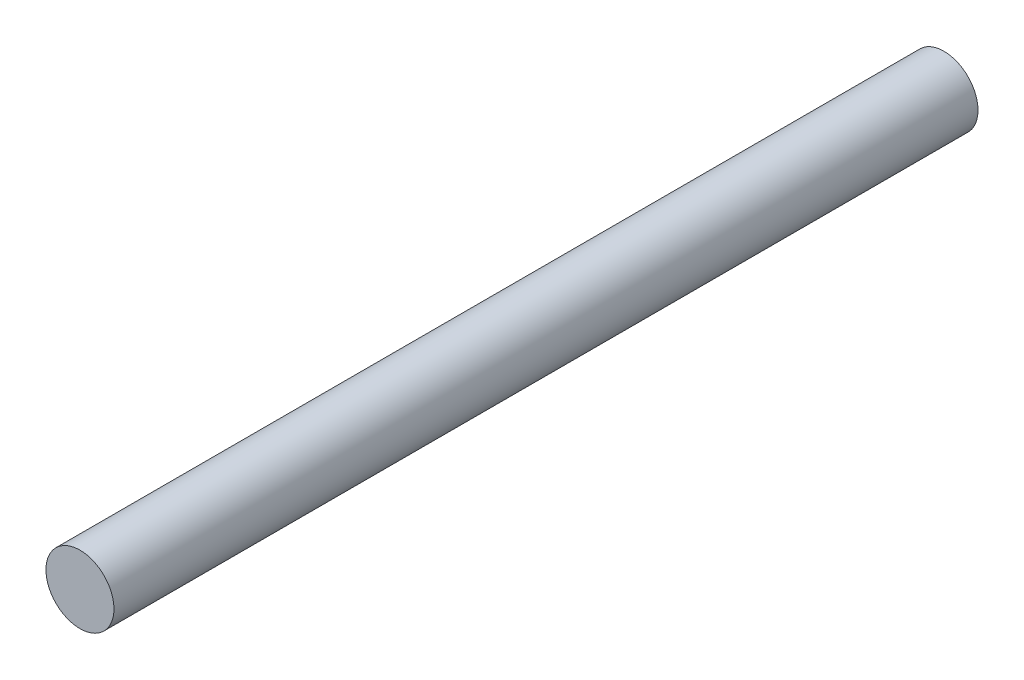
from build123d import *

# Parameters (mm, degrees)
SKETCH1_R           = 3
BOSS_EXTRUDE1_DEPTH = 76.2


with BuildPart() as part:
    # Sketch1 → Boss-Extrude1 (new body)
    with BuildSketch(Plane.XY):
        Circle(SKETCH1_R)
    extrude(amount=BOSS_EXTRUDE1_DEPTH)


solid = part.part
